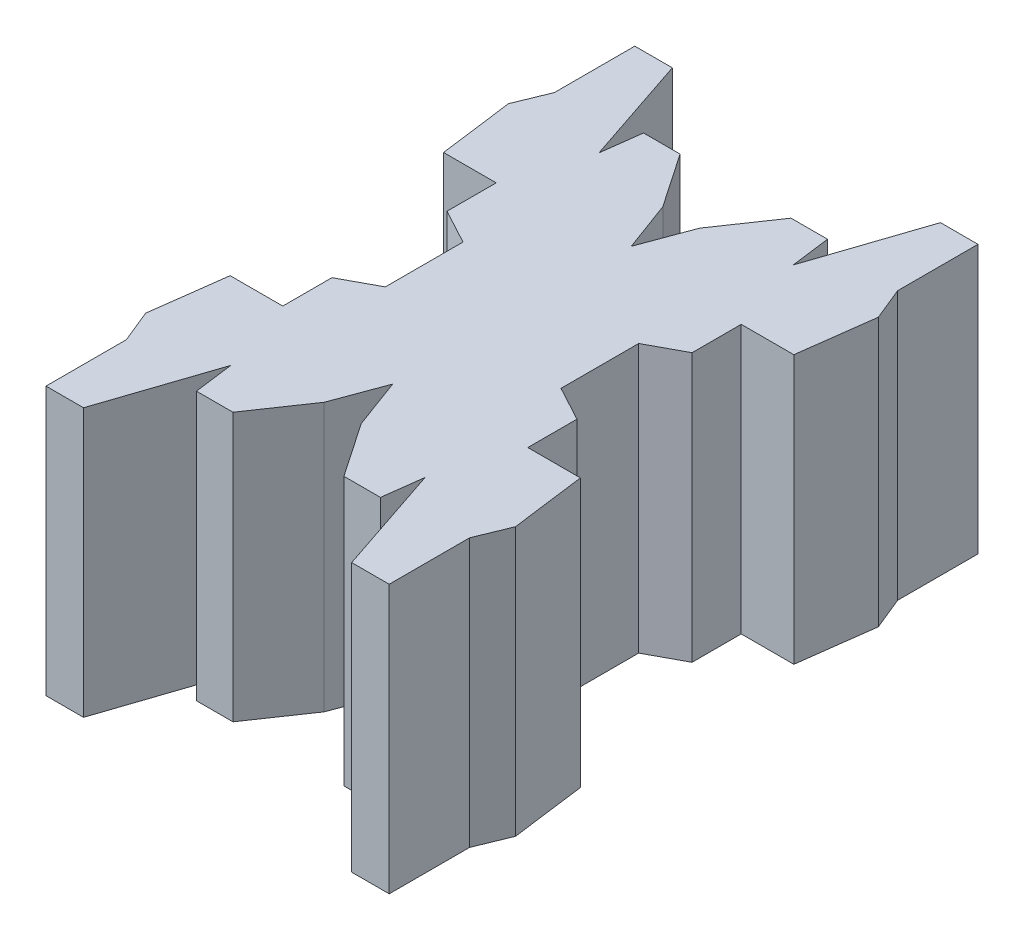
from build123d import *

# Parameters (mm, degrees)
BOSS_EXTRUDE1_DEPTH = 29


with BuildPart() as part:
    # Sketch1 → Boss-Extrude1 (new body)
    with BuildSketch(Plane(origin=(0, 0, 0), x_dir=(1, 0, 0), z_dir=(0, 1, 0))):
        Polygon((24.759890606, 17.762425379), (28.759890606, 29.702343473), (29.307835455, 25.423793289), (33.259890606, 25.423793289), (37.259890606, 31.293559553), (39.259890606, 36.702343473), (41.259890606, 31.293559553), (45.259890606, 25.423793289), (49.211945756, 25.423793289), (49.759890606, 29.702343473), (53.759890606, 17.762425379), (57.818331734, 17.762425379), (57.818331734, 26.457588678), (59.259890606, 29.980893658), (58.200604263, 38.06142419), (52.509890606, 38.06142419), (52.509890606, 43.377759071), (48.759890606, 45.399346339), (48.759890606, 53.802982108), (52.509890606, 55.824569376), (52.509890606, 61.140904257), (58.200604263, 61.140904257), (59.259890606, 69.221434789), (57.818331734, 72.744739769), (57.818331734, 81.439903068), (53.759890606, 81.439903068), (49.759890606, 69.499984974), (49.211945756, 73.778535158), (45.259890606, 73.778535158), (41.259890606, 67.908768894), (39.259890606, 62.499984974), (37.259890606, 67.908768894), (33.259890606, 73.778535158), (29.307835455, 73.778535158), (28.759890606, 69.499984974), (24.759890606, 81.439903068), (20.701449477, 81.439903068), (20.701449477, 72.744739769), (19.259890606, 69.221434789), (20.319176948, 61.140904257), (26.009890606, 61.140904257), (26.009890606, 55.824569376), (29.759890606, 53.802982108), (29.759890606, 45.399346339), (26.009890606, 43.377759071), (26.009890606, 38.06142419), (20.319176948, 38.06142419), (19.259890606, 29.980893658), (20.701449477, 26.457588678), (20.701449477, 17.762425379), align=None)
    extrude(amount=BOSS_EXTRUDE1_DEPTH)


solid = part.part
